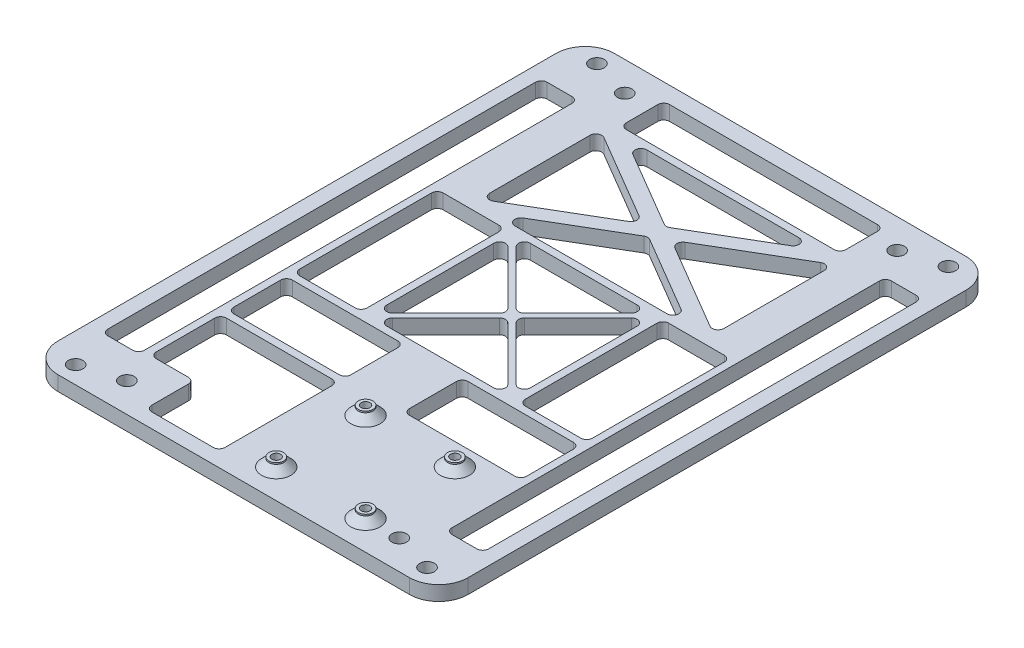
from build123d import *

# Parameters (mm, degrees)
SKETCH1_W           = 140
SKETCH1_H           = 190
SKETCH1_R           = 2.5
BOSS_EXTRUDE1_DEPTH = 5
FILLET1_R           = 10
SKETCH3_R           = 1.5
CUT_EXTRUDE2_DEPTH  = 10
SKETCH14_W          = 12.5
SKETCH14_H          = 150
CUT_EXTRUDE9_DEPTH  = 10
FILLET3_R           = 2
SKETCH17_R          = 2.5
CUT_EXTRUDE12_DEPTH = 10
SKETCH18_R          = 2.5
SKETCH18_R_2        = 1.5
BOSS_EXTRUDE2_DEPTH = 3
CUT_EXTRUDE13_DEPTH = 6
CHAMFER1_SIZE       = 2.5


with BuildPart() as part:
    # Sketch1 → Boss-Extrude1 (new body)
    with BuildSketch(Plane(origin=(0, 0, 0), x_dir=(1, 0, 0), z_dir=(0, 1, 0))):
        Rectangle(SKETCH1_W, SKETCH1_H)
        with Locations((60, -89)):
            Circle(SKETCH1_R, mode=Mode.SUBTRACT)
        with Locations((60, 89)):
            Circle(SKETCH1_R, mode=Mode.SUBTRACT)
        with Locations((-60, 89)):
            Circle(SKETCH1_R, mode=Mode.SUBTRACT)
        with Locations((-60, -89)):
            Circle(SKETCH1_R, mode=Mode.SUBTRACT)
    extrude(amount=BOSS_EXTRUDE1_DEPTH)

    # Fillet1
    fillet1_edges = [part.edges().sort_by_distance(p)[0] for p in [
        (-70, 2.5, 95),
        (-70, 2.5, -95),
        (70, 2.5, -95),
        (70, 2.5, 95),
    ]]
    fillet(fillet1_edges, radius=FILLET1_R)

    # Sketch3 → Cut-Extrude2 (cut)
    with BuildSketch(Plane(origin=(0, 5, 0), x_dir=(1, 0, 0), z_dir=(0, 1, 0))):
        with Locations((4.5, -54.5)):
            Circle(SKETCH3_R)
        with Locations((35, -54.5)):
            Circle(SKETCH3_R)
        with Locations((4.5, -85)):
            Circle(SKETCH3_R)
        with Locations((35, -85)):
            Circle(SKETCH3_R)
    extrude(amount=-CUT_EXTRUDE2_DEPTH, mode=Mode.SUBTRACT)

    # Sketch14 → Cut-Extrude9 (cut)
    with BuildSketch(Plane(origin=(0, 5, 0), x_dir=(1, 0, 0), z_dir=(0, 1, 0))):
        with Locations((-58.75, 0)):
            Rectangle(SKETCH14_W, SKETCH14_H)
        with Locations((58.75, 0)):
            Rectangle(SKETCH14_W, SKETCH14_H)
        Polygon((-35, -49.5), (-10, -49.5), (-10, -90), (-35, -90), (-35, -73.5), (-50, -73.5), (-50, -49.5), align=None)
        with BuildLine():
            Line((-35.5, 89.3), (35.5, 89.3))
            ThreePointArc((35.5, 89.3), (36.914213562, 88.714213562), (37.5, 87.3))
            Line((37.5, 87.3), (37.5, 76.5))
            ThreePointArc((37.5, 76.5), (36.914213562, 75.085786438), (35.5, 74.5))
            Line((35.5, 74.5), (-35.5, 74.5))
            ThreePointArc((-35.5, 74.5), (-36.914213562, 75.085786438), (-37.5, 76.5))
            Line((-37.5, 76.5), (-37.5, 87.3))
            ThreePointArc((-37.5, 87.3), (-36.914213562, 88.714213562), (-35.5, 89.3))
        make_face()
        Polygon((-24.5, -23.085786438), (-1.414213562, 0), (-24.5, 23.085786438), align=None)
        Polygon((23.085786438, 24.5), (-23.085786438, 24.5), (0, 1.414213562), align=None)
        Polygon((24.5, -23.085786438), (24.5, 23.085786438), (1.414213562, 0), align=None)
        Polygon((-23.085786438, -24.5), (23.085786438, -24.5), (0, -1.414213562), align=None)
    extrude(amount=-CUT_EXTRUDE9_DEPTH, mode=Mode.SUBTRACT)

    # Fillet3
    fillet3_edges = [part.edges().sort_by_distance(p)[0] for p in [
        (-65, 2.5, 75),
        (-65, 2.5, -75),
        (-52.5, 2.5, -75),
        (-52.5, 2.5, 75),
        (1.414213562, 2.5, 0),
        (24.5, 2.5, -23.085786438),
        (24.5, 2.5, 23.085786438),
        (0, 2.5, -1.414213562),
        (-23.085786438, 2.5, -24.5),
        (23.085786438, 2.5, -24.5),
        (0, 2.5, 1.414213562),
        (23.085786438, 2.5, 24.5),
        (-23.085786438, 2.5, 24.5),
        (-50, 2.5, 49.5),
        (-10, 2.5, 49.5),
        (-10, 2.5, 90),
        (-35, 2.5, 90),
        (-35, 2.5, 73.5),
        (-50, 2.5, 73.5),
        (65, 2.5, -75),
        (65, 2.5, 75),
        (52.5, 2.5, 75),
        (52.5, 2.5, -75),
        (-24.5, 2.5, 23.085786438),
        (-24.5, 2.5, -23.085786438),
        (-1.414213562, 2.5, 0),
    ]]
    fillet(fillet3_edges, radius=FILLET3_R)

    # Sketch17 → Cut-Extrude12 (cut)
    with BuildSketch(Plane(origin=(0, 5, 0), x_dir=(1, 0, 0), z_dir=(0, 1, 0))):
        with Locations((46.5, 85)):
            Circle(SKETCH17_R)
        with Locations((46.5, -85)):
            Circle(SKETCH17_R)
        with Locations((-46.5, -85)):
            Circle(SKETCH17_R)
        with Locations((-46.5, 85)):
            Circle(SKETCH17_R)
    extrude(amount=-CUT_EXTRUDE12_DEPTH, mode=Mode.SUBTRACT)

    # Sketch18 → Boss-Extrude2 (add)
    with BuildSketch(Plane(origin=(0, 5, 0), x_dir=(1, 0, 0), z_dir=(0, 1, 0))):
        with Locations((4.5, -54.5)):
            Circle(SKETCH18_R)
        with Locations((4.5, -54.5)):
            Circle(SKETCH18_R_2, mode=Mode.SUBTRACT)
        with Locations((35, -54.5)):
            Circle(SKETCH18_R)
        with Locations((35, -54.5)):
            Circle(SKETCH18_R_2, mode=Mode.SUBTRACT)
        with Locations((35, -85)):
            Circle(SKETCH18_R)
        with Locations((35, -85)):
            Circle(SKETCH18_R_2, mode=Mode.SUBTRACT)
        with Locations((4.5, -85)):
            Circle(SKETCH18_R)
        with Locations((4.5, -85)):
            Circle(SKETCH18_R_2, mode=Mode.SUBTRACT)
    extrude(amount=BOSS_EXTRUDE2_DEPTH)

    # Sketch19 → Cut-Extrude13 (cut, through all)
    with BuildSketch(Plane(origin=(0, 5, 0), x_dir=(1, 0, 0), z_dir=(0, 1, 0))):
        with BuildLine():
            Line((-48, -47), (-12, -47))
            ThreePointArc((-12, -47), (-10.585786438, -46.414213562), (-10, -45))
            Line((-10, -45), (-10, -29))
            ThreePointArc((-10, -29), (-10.585786438, -27.585786438), (-12, -27))
            Line((-12, -27), (-48, -27))
            ThreePointArc((-48, -27), (-49.414213562, -27.585786438), (-50, -29))
            Line((-50, -29), (-50, -45))
            ThreePointArc((-50, -45), (-49.414213562, -46.414213562), (-48, -47))
        make_face()
        with BuildLine():
            Line((50, -45), (50, -29))
            ThreePointArc((50, -29), (49.414213562, -27.585786438), (48, -27))
            Line((48, -27), (12, -27))
            ThreePointArc((12, -27), (10.585786438, -27.585786438), (10, -29))
            Line((10, -29), (10, -45))
            ThreePointArc((10, -45), (10.585786438, -46.414213562), (12, -47))
            Line((12, -47), (48, -47))
            ThreePointArc((48, -47), (49.414213562, -46.414213562), (50, -45))
        make_face()
        with BuildLine():
            Line((-48, -24.5), (-29, -24.5))
            ThreePointArc((-29, -24.5), (-27.585786438, -23.914213562), (-27, -22.5))
            Line((-27, -22.5), (-27, 22.5))
            ThreePointArc((-27, 22.5), (-27.585786438, 23.914213562), (-29, 24.5))
            Line((-29, 24.5), (-48, 24.5))
            ThreePointArc((-48, 24.5), (-49.414213562, 23.914213562), (-50, 22.5))
            Line((-50, 22.5), (-50, -22.5))
            ThreePointArc((-50, -22.5), (-49.414213562, -23.914213562), (-48, -24.5))
        make_face()
        with BuildLine():
            Line((48, 24.5), (29, 24.5))
            ThreePointArc((29, 24.5), (27.585786438, 23.914213562), (27, 22.5))
            Line((27, 22.5), (27, -22.5))
            ThreePointArc((27, -22.5), (27.585786438, -23.914213562), (29, -24.5))
            Line((29, -24.5), (48, -24.5))
            ThreePointArc((48, -24.5), (49.414213562, -23.914213562), (50, -22.5))
            Line((50, -22.5), (50, 22.5))
            ThreePointArc((50, 22.5), (49.414213562, 23.914213562), (48, 24.5))
        make_face()
        with BuildLine():
            Line((-40, 66.632125109), (-40, 32.367874891))
            ThreePointArc((-40, 32.367874891), (-38.992955058, 30.631775743), (-36.985959747, 30.644006461))
            Line((-36.985959747, 30.644006461), (-7.861347062, 47.77613157))
            ThreePointArc((-7.861347062, 47.77613157), (-6.875387315, 49.5), (-7.861347062, 51.22386843))
            Line((-7.861347062, 51.22386843), (-36.985959747, 68.355993539))
            ThreePointArc((-36.985959747, 68.355993539), (-38.992955058, 68.368224257), (-40, 66.632125109))
        make_face()
        with BuildLine():
            Line((-26.988652938, 68.27613157), (-1.014040253, 52.996947638))
            ThreePointArc((-1.014040253, 52.996947638), (0, 52.720816068), (1.014040253, 52.996947638))
            Line((1.014040253, 52.996947638), (26.988652938, 68.27613157))
            ThreePointArc((26.988652938, 68.27613157), (27.90434542, 70.525482226), (25.974612685, 72))
            Line((25.974612685, 72), (-25.974612685, 72))
            ThreePointArc((-25.974612685, 72), (-27.90434542, 70.525482226), (-26.988652938, 68.27613157))
        make_face()
        with BuildLine():
            Line((36.985959747, 30.644006461), (7.861347062, 47.77613157))
            ThreePointArc((7.861347062, 47.77613157), (6.875387315, 49.5), (7.861347062, 51.22386843))
            Line((7.861347062, 51.22386843), (36.985959747, 68.355993539))
            ThreePointArc((36.985959747, 68.355993539), (38.992955058, 68.368224257), (40, 66.632125109))
            Line((40, 66.632125109), (40, 32.367874891))
            ThreePointArc((40, 32.367874891), (38.992955058, 30.631775743), (36.985959747, 30.644006461))
        make_face()
        with BuildLine():
            Line((1.014040253, 46.003052362), (26.988652938, 30.72386843))
            ThreePointArc((26.988652938, 30.72386843), (27.90434542, 28.474517774), (25.974612685, 27))
            Line((25.974612685, 27), (-25.974612685, 27))
            ThreePointArc((-25.974612685, 27), (-27.90434542, 28.474517774), (-26.988652938, 30.72386843))
            Line((-26.988652938, 30.72386843), (-1.014040253, 46.003052362))
            ThreePointArc((-1.014040253, 46.003052362), (0, 46.279183932), (1.014040253, 46.003052362))
        make_face()
    extrude(amount=-CUT_EXTRUDE13_DEPTH, mode=Mode.SUBTRACT)

    # Chamfer1
    chamfer1_edges = [part.edges().sort_by_distance(p)[0] for p in [
        (2, 5, 54.5),
        (32.5, 5, 54.5),
        (32.5, 5, 85),
        (2, 5, 85),
    ]]
    chamfer(chamfer1_edges, length=CHAMFER1_SIZE)


solid = part.part
